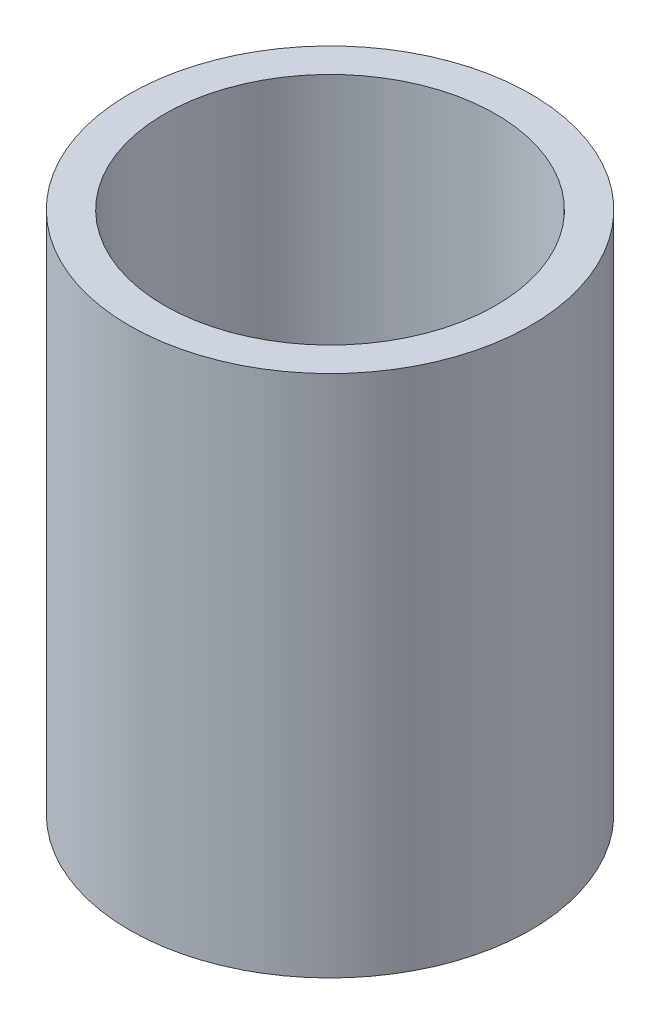
from build123d import *

# Parameters (mm, degrees)
SKETCH1_R           = 2.3
SKETCH1_R_2         = 1.9
BOSS_EXTRUDE1_DEPTH = 6


with BuildPart() as part:
    # Sketch1 → Boss-Extrude1 (new body)
    with BuildSketch(Plane(origin=(0, 0, 0), x_dir=(1, 0, 0), z_dir=(0, 1, 0))):
        with Locations((-0.929485335, 1.206700259)):
            Circle(SKETCH1_R)
        with Locations((-0.929485335, 1.206700259)):
            Circle(SKETCH1_R_2, mode=Mode.SUBTRACT)
    extrude(amount=BOSS_EXTRUDE1_DEPTH)


solid = part.part
